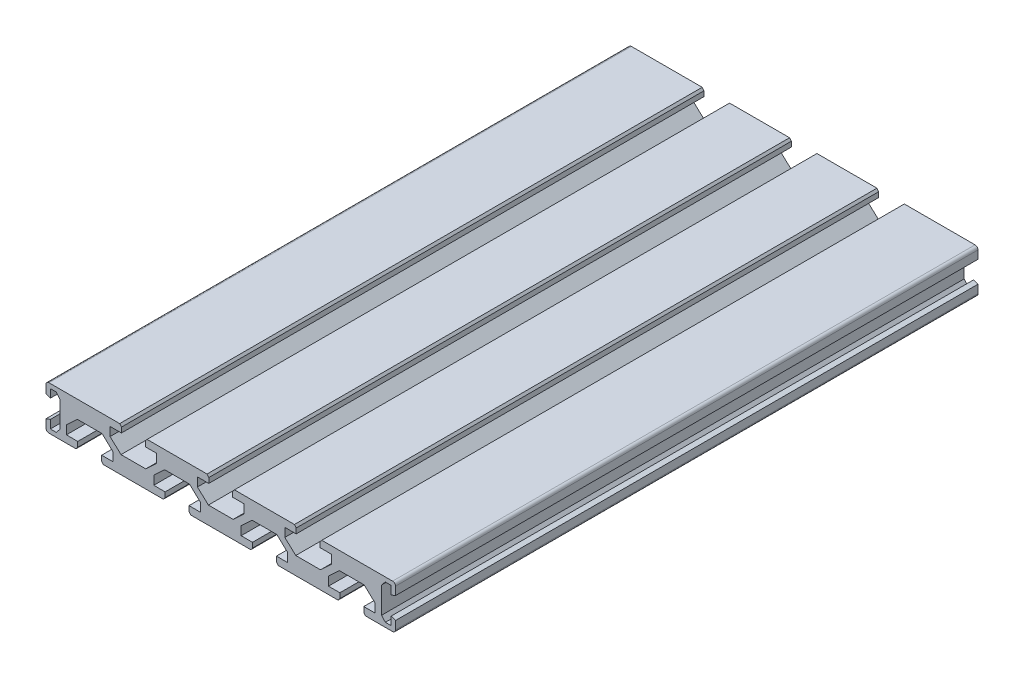
from build123d import *

# Parameters (mm, degrees)
BOSS_EXTRUDE1_DEPTH = 200


with BuildPart() as part:
    # Sketch1 → Boss-Extrude1 (new body)
    with BuildSketch(Plane.XY):
        with BuildLine():
            Line((0, -3.8), (0, -1))
            ThreePointArc((0, -1), (0.292893219, -0.292893219), (1, 0))
            Line((1, 0), (15, 0))
            Line((15, 0), (23.02057349, 0))
            Line((23.02057349, 0), (25.3, 0))
            Line((25.3, 0), (25.9, -0.75))
            Line((25.9, -0.75), (25.9, -2.5))
            Line((25.9, -2.5), (22, -2.5))
            Line((22, -2.5), (22, -5.5))
            Line((22, -5.5), (25.75, -9))
            Line((25.75, -9), (30, -9))
            Line((30, -9), (34.25, -9))
            Line((34.25, -9), (38, -5.5))
            Line((38, -5.5), (38, -2.5))
            Line((38, -2.5), (34.1, -2.5))
            Line((34.1, -2.5), (34.1, -0.75))
            Line((34.1, -0.75), (34.7, 0))
            Line((34.7, 0), (55.3, 0))
            Line((55.3, 0), (55.9, -0.75))
            Line((55.9, -0.75), (55.9, -2.5))
            Line((55.9, -2.5), (52, -2.5))
            Line((52, -2.5), (52, -5.5))
            Line((52, -5.5), (55.75, -9))
            Line((55.75, -9), (60, -9))
            Line((60, -9), (64.25, -9))
            Line((64.25, -9), (68, -5.5))
            Line((68, -5.5), (68, -2.5))
            Line((68, -2.5), (64.1, -2.5))
            Line((64.1, -2.5), (64.1, -0.75))
            Line((64.1, -0.75), (64.7, 0))
            Line((64.7, 0), (85.3, 0))
            Line((85.3, 0), (85.9, -0.75))
            Line((85.9, -0.75), (85.9, -2.5))
            Line((85.9, -2.5), (82, -2.5))
            Line((82, -2.5), (82, -5.5))
            Line((82, -5.5), (85.75, -9))
            Line((85.75, -9), (90, -9))
            Line((90, -9), (94.25, -9))
            Line((94.25, -9), (98, -5.5))
            Line((98, -5.5), (98, -2.5))
            Line((98, -2.5), (94.1, -2.5))
            Line((94.1, -2.5), (94.1, -0.75))
            Line((94.1, -0.75), (94.7, 0))
            Line((94.7, 0), (95.680089514, 0))
            Line((95.680089514, 0), (119, 0))
            ThreePointArc((119, 0), (119.707106781, -0.292893219), (120, -1))
            Line((120, -1), (120, -3.8))
            Line((120, -3.8), (118.5, -4.35))
            Line((118.5, -4.35), (118.5, -1.5))
            Line((118.5, -1.5), (116.5, -1.5))
            Line((116.5, -1.5), (115.25, -3))
            Line((115.25, -3), (115.25, -12))
            Line((115.25, -12), (116.5, -13.5))
            Line((116.5, -13.5), (118.5, -13.5))
            Line((118.5, -13.5), (118.5, -10.65))
            Line((118.5, -10.65), (120, -11.2))
            Line((120, -11.2), (120, -14))
            ThreePointArc((120, -14), (119.707106781, -14.707106781), (119, -15))
            Line((119, -15), (109.7, -15))
            Line((109.7, -15), (109.1, -14.25))
            Line((109.1, -14.25), (109.1, -12.5))
            Line((109.1, -12.5), (113, -12.5))
            Line((113, -12.5), (113, -9.5))
            Line((113, -9.5), (109.25, -6))
            Line((109.25, -6), (105, -6))
            Line((105, -6), (100.75, -6))
            Line((100.75, -6), (97, -9.5))
            Line((97, -9.5), (97, -12.5))
            Line((97, -12.5), (100.9, -12.5))
            Line((100.9, -12.5), (100.9, -14.25))
            Line((100.9, -14.25), (100.3, -15))
            Line((100.3, -15), (79.7, -15))
            Line((79.7, -15), (79.1, -14.25))
            Line((79.1, -14.25), (79.1, -12.5))
            Line((79.1, -12.5), (83, -12.5))
            Line((83, -12.5), (83, -9.5))
            Line((83, -9.5), (79.25, -6))
            Line((79.25, -6), (75, -6))
            Line((75, -6), (70.75, -6))
            Line((70.75, -6), (67, -9.5))
            Line((67, -9.5), (67, -12.5))
            Line((67, -12.5), (70.9, -12.5))
            Line((70.9, -12.5), (70.9, -14.25))
            Line((70.9, -14.25), (70.3, -15))
            Line((70.3, -15), (49.7, -15))
            Line((49.7, -15), (49.1, -14.25))
            Line((49.1, -14.25), (49.1, -12.5))
            Line((49.1, -12.5), (53, -12.5))
            Line((53, -12.5), (53, -9.5))
            Line((53, -9.5), (49.25, -6))
            Line((49.25, -6), (45, -6))
            Line((45, -6), (40.75, -6))
            Line((40.75, -6), (37, -9.5))
            Line((37, -9.5), (37, -12.5))
            Line((37, -12.5), (40.9, -12.5))
            Line((40.9, -12.5), (40.9, -14.25))
            Line((40.9, -14.25), (40.3, -15))
            Line((40.3, -15), (19.7, -15))
            Line((19.7, -15), (19.1, -14.25))
            Line((19.1, -14.25), (19.1, -12.5))
            Line((19.1, -12.5), (23, -12.5))
            Line((23, -12.5), (23, -9.5))
            Line((23, -9.5), (19.25, -6))
            Line((19.25, -6), (15, -6))
            Line((15, -6), (10.75, -6))
            Line((10.75, -6), (7, -9.5))
            Line((7, -9.5), (7, -12.5))
            Line((7, -12.5), (10.9, -12.5))
            Line((10.9, -12.5), (10.9, -14.25))
            Line((10.9, -14.25), (10.3, -15))
            Line((10.3, -15), (1, -15))
            ThreePointArc((1, -15), (0.292893219, -14.707106781), (0, -14))
            Line((0, -14), (0, -11.2))
            Line((0, -11.2), (1.5, -10.65))
            Line((1.5, -10.65), (1.5, -13.5))
            Line((1.5, -13.5), (3.5, -13.5))
            Line((3.5, -13.5), (4.75, -12))
            Line((4.75, -12), (4.75, -3))
            Line((4.75, -3), (3.5, -1.5))
            Line((3.5, -1.5), (1.5, -1.5))
            Line((1.5, -1.5), (1.5, -4.35))
            Line((1.5, -4.35), (0, -3.8))
        make_face()
    extrude(amount=-BOSS_EXTRUDE1_DEPTH)


solid = part.part
